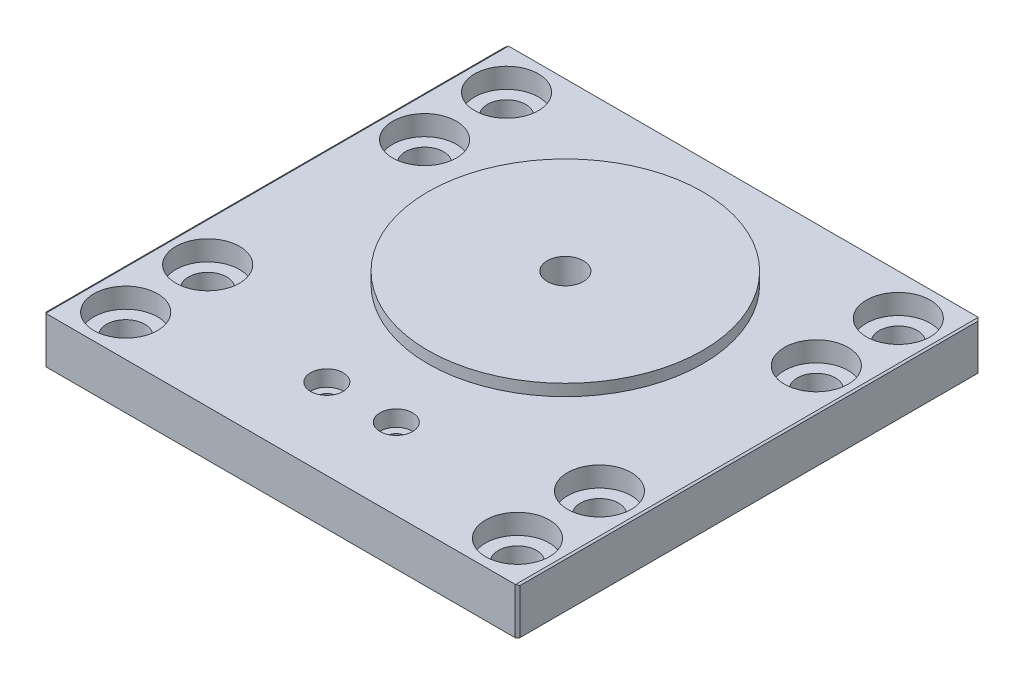
from build123d import *

# Parameters (mm, degrees)
SKETCH1_W                                      = 104.000000026
SKETCH1_H                                      = 101.6
BOSS_EXTRUDE1_DEPTH                            = 10.16
SKETCH5_R                                      = 30.1625
BOSS_EXTRUDE2_DEPTH                            = 2.54
CBORE_FOR_6_SOCKET_HEAD_CAP_SCREW1_D           = 3.7973
CBORE_FOR_6_SOCKET_HEAD_CAP_SCREW1_CBORE_D     = 7.14502
CBORE_FOR_6_SOCKET_HEAD_CAP_SCREW1_CBORE_DEPTH = 3.5052
F_3_8_16_TAPPED_HOLE1_D                        = 7.9375
CBORE_FOR_M8_SBHCS1_D                          = 8.4
CBORE_FOR_M8_SBHCS1_CBORE_D                    = 14
CBORE_FOR_M8_SBHCS1_CBORE_DEPTH                = 4.4
CHAMFER1_SIZE                                  = 0.254
CHAMFER1_SIZE2                                 = 0.439940905
CHAMFER1_PART_2_SIZE                           = 0.254
CHAMFER1_PART_2_SIZE2                          = 0.439940905
CHAMFER2_SIZE                                  = 0.508


with BuildPart() as part:
    # Sketch1 → Boss-Extrude1 (new body)
    with BuildSketch(Plane(origin=(0, 0, 0), x_dir=(1, 0, 0), z_dir=(0, 1, 0))):
        with Locations((-52.000000013, 50.8)):
            Rectangle(SKETCH1_W, SKETCH1_H)
    extrude(amount=BOSS_EXTRUDE1_DEPTH)

    # Sketch5 → Boss-Extrude2 (add)
    with BuildSketch(Plane(origin=(0, 10.16, 0), x_dir=(1, 0, 0), z_dir=(0, 1, 0))):
        with Locations((-52.000000013, 62.5094)):
            Circle(SKETCH5_R)
    extrude(amount=BOSS_EXTRUDE2_DEPTH)

    # CBORE for #6 Socket Head Cap Screw1 (through all)
    with Locations(Plane(origin=(0, 10.16, 0), x_dir=(1, 0, 0), z_dir=(0, 1, 0))):
        with Locations((-44.380000013, 17.78), (-59.620000013, 17.78)):
            CounterBoreHole(CBORE_FOR_6_SOCKET_HEAD_CAP_SCREW1_D / 2, CBORE_FOR_6_SOCKET_HEAD_CAP_SCREW1_CBORE_D / 2, CBORE_FOR_6_SOCKET_HEAD_CAP_SCREW1_CBORE_DEPTH)

    # 3/8-16 Tapped Hole1 (through all)
    with Locations(Plane(origin=(0, 12.7, 0), x_dir=(1, 0, 0), z_dir=(0, 1, 0))):
        with Locations((-52.000000013, 62.5094)):
            Hole(F_3_8_16_TAPPED_HOLE1_D / 2)

    # CBORE for M8 SBHCS1 (through all)
    with Locations(Plane(origin=(0, 10.16, 0), x_dir=(1, 0, 0), z_dir=(0, 1, 0))):
        with Locations((-8.999999961, 92.6), (-8.999999961, 74.6), (-8.999999961, 27), (-8.999999961, 9), (-95.000000013, 9), (-95.000000013, 27), (-95.000000013, 74.6), (-95.000000013, 92.6)):
            CounterBoreHole(CBORE_FOR_M8_SBHCS1_D / 2, CBORE_FOR_M8_SBHCS1_CBORE_D / 2, CBORE_FOR_M8_SBHCS1_CBORE_DEPTH)

    # Chamfer1
    chamfer1_edges = [part.edges().sort_by_distance(p)[0] for p in [
        (0, 10.16, -50.8),
    ]]
    chamfer1_side = [part.faces().sort_by_distance(p)[0] for p in [
        (0, 5.08, -50.8),
    ]]
    chamfer(chamfer1_edges, length=CHAMFER1_SIZE, length2=CHAMFER1_SIZE2, reference=chamfer1_side[0])

    # Chamfer1 part 2
    chamfer1_part_2_edges = [part.edges().sort_by_distance(p)[0] for p in [
        (-104.000000026, 10.16, -50.8),
    ]]
    chamfer1_part_2_side = [part.faces().sort_by_distance(p)[0] for p in [
        (-104.000000026, 5.08, -50.8),
    ]]
    chamfer(chamfer1_part_2_edges, length=CHAMFER1_PART_2_SIZE, length2=CHAMFER1_PART_2_SIZE2, reference=chamfer1_part_2_side[0])

    # Chamfer2
    chamfer2_edges = [part.edges().sort_by_distance(p)[0] for p in [
        (0, 4.953, 0),
        (-104.000000026, 4.953, 0),
        (-104.000000026, 4.953, -101.6),
        (0, 4.953, -101.6),
    ]]
    chamfer(chamfer2_edges, length=CHAMFER2_SIZE)


solid = part.part
